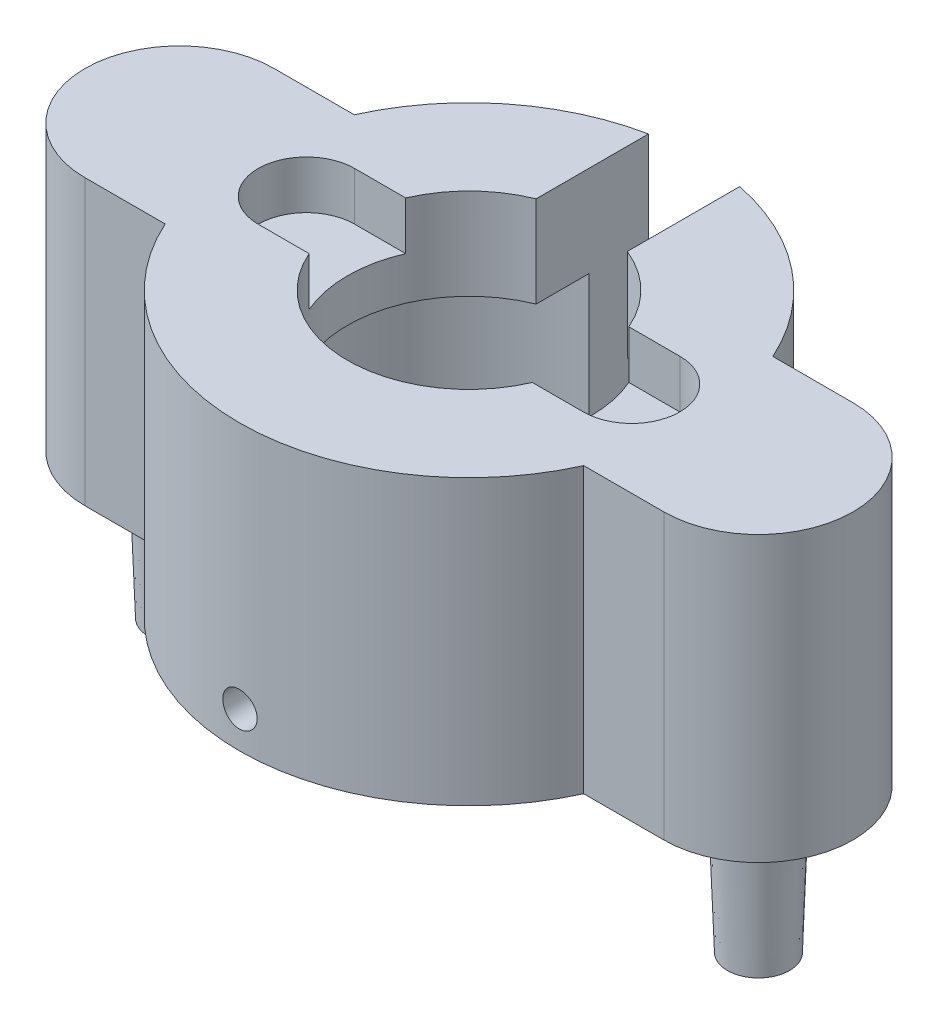
from build123d import *

# Parameters (mm, degrees)
SKETCH1_R             = 11.303
BOSS_EXTRUDE1_DEPTH   = 12.7
F_4_40_TAPPED_HOLE1_D = 2.2606
SKETCH10_R            = 2.38125
BOSS_EXTRUDE2_DEPTH   = 9.525
BOSS_EXTRUDE2_TAPER   = 2
SKETCH14_R            = 11.303
SKETCH14_R_2          = 8
BOSS_EXTRUDE3_DEPTH   = 6
SKETCH20_W            = 6
SKETCH20_H            = 15.993334041
CUT_EXTRUDE3_DEPTH    = 29.2250001
CUT_EXTRUDE4_DEPTH    = 3.175


with BuildPart() as part:
    # Sketch1 → Boss-Extrude1 (new body)
    with BuildSketch(Plane(origin=(0, 0, 0), x_dir=(1, 0, 0), z_dir=(0, 1, 0))):
        with BuildLine():
            Line((-19.05, 6.223), (-13.772328779, 6.223))
            ThreePointArc((-13.772328779, 6.223), (0, 15.113), (13.772328779, 6.223))
            Line((13.772328779, 6.223), (19.05, 6.223))
            ThreePointArc((19.05, 6.223), (25.273, 0), (19.05, -6.223))
            Line((19.05, -6.223), (13.772328779, -6.223))
            ThreePointArc((13.772328779, -6.223), (0, -15.113), (-13.772328779, -6.223))
            Line((-13.772328779, -6.223), (-19.05, -6.223))
            ThreePointArc((-19.05, -6.223), (-25.273, 0), (-19.05, 6.223))
        make_face()
        Circle(SKETCH1_R, mode=Mode.SUBTRACT)
    extrude(amount=BOSS_EXTRUDE1_DEPTH)

    # #4-40 Tapped Hole1 (through all)
    with Locations(Plane.XY.offset(15.113)):
        with Locations((0, 2.38125)):
            Hole(F_4_40_TAPPED_HOLE1_D / 2)

    # Sketch10 → Boss-Extrude2 (add)
    with BuildSketch(Plane.XZ):
        with Locations((-19.05, 0)):
            Circle(SKETCH10_R)
        with Locations((19.05, 0)):
            Circle(SKETCH10_R)
    extrude(amount=BOSS_EXTRUDE2_DEPTH, taper=BOSS_EXTRUDE2_TAPER)

    # Sketch14 → Boss-Extrude3 (add)
    with BuildSketch(Plane(origin=(0, 12.7, 0), x_dir=(1, 0, 0), z_dir=(0, 1, 0))):
        with BuildLine():
            ThreePointArc((13.772328779, 6.223), (14.774030828, 3.182888952), (15.113, 0))
            ThreePointArc((15.113, 0), (14.774030828, -3.182888952), (13.772328779, -6.223))
            Line((13.772328779, -6.223), (19.05, -6.223))
            ThreePointArc((19.05, -6.223), (25.273, 0), (19.05, 6.223))
            Line((19.05, 6.223), (13.772328779, 6.223))
        make_face()
        with BuildLine():
            ThreePointArc((-13.772328779, -6.223), (-15.113, 0), (-13.772328779, 6.223))
            Line((-13.772328779, 6.223), (-19.05, 6.223))
            ThreePointArc((-19.05, 6.223), (-25.273, 0), (-19.05, -6.223))
            Line((-19.05, -6.223), (-13.772328779, -6.223))
        make_face()
        with BuildLine():
            ThreePointArc((13.772328779, -6.223), (14.774030828, -3.182888952), (15.113, 0))
            ThreePointArc((15.113, 0), (14.774030828, 3.182888952), (13.772328779, 6.223))
            ThreePointArc((13.772328779, 6.223), (0, 15.113), (-13.772328779, 6.223))
            ThreePointArc((-13.772328779, 6.223), (-15.113, 0), (-13.772328779, -6.223))
            ThreePointArc((-13.772328779, -6.223), (0, -15.113), (13.772328779, -6.223))
        make_face()
        Circle(SKETCH14_R, mode=Mode.SUBTRACT)
        Circle(SKETCH14_R)
        Circle(SKETCH14_R_2, mode=Mode.SUBTRACT)
    extrude(amount=BOSS_EXTRUDE3_DEPTH)

    # Sketch20 → Cut-Extrude3 (cut, through all)
    with BuildSketch(Plane(origin=(0, 18.7, 0), x_dir=(1, 0, 0), z_dir=(0, 1, 0))):
        with Locations((0, 10.151613004)):
            Rectangle(SKETCH20_W, SKETCH20_H)
    extrude(amount=-CUT_EXTRUDE3_DEPTH, mode=Mode.SUBTRACT)

    # Sketch21 → Cut-Extrude4 (cut)
    with BuildSketch(Plane(origin=(0, 18.7, 0), x_dir=(1, 0, 0), z_dir=(0, 1, 0))):
        with BuildLine():
            Line((-10.700000063, 3.175), (10.700000063, 3.175))
            ThreePointArc((10.700000063, 3.175), (13.875000063, 0), (10.700000063, -3.175))
            Line((10.700000063, -3.175), (-10.700000063, -3.175))
            ThreePointArc((-10.700000063, -3.175), (-13.875000063, 0), (-10.700000063, 3.175))
        make_face()
    extrude(amount=-CUT_EXTRUDE4_DEPTH, mode=Mode.SUBTRACT)


solid = part.part
